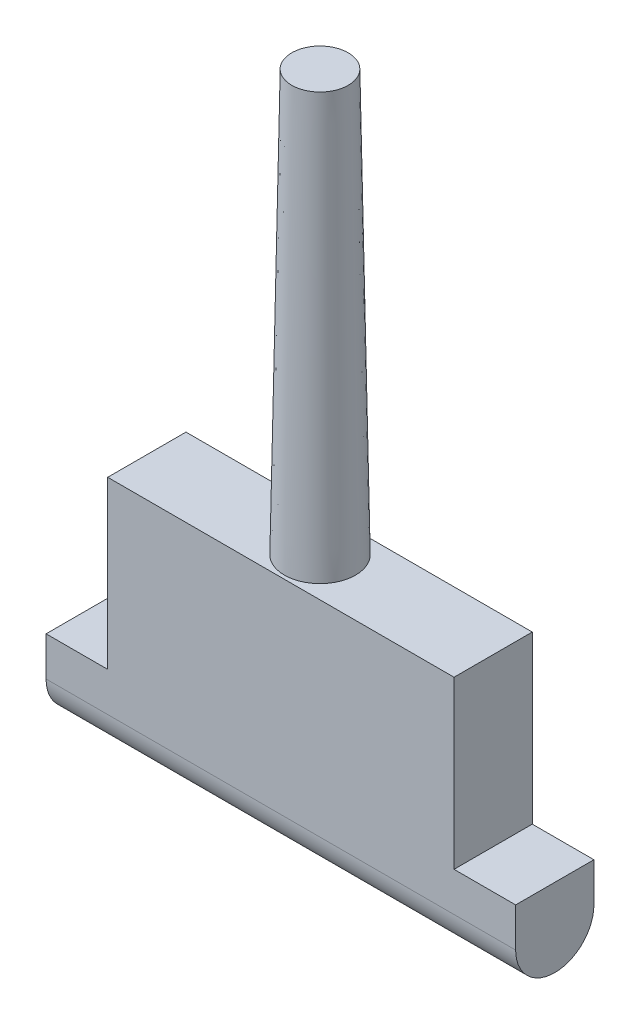
from build123d import *

# Parameters (mm, degrees)
BOSS_EXTRUDE1_DEPTH = 19.05
SKETCH2_R           = 3.175
BOSS_EXTRUDE2_DEPTH = 50.8
BOSS_EXTRUDE2_TAPER = 1
SKETCH3_W           = 28.1
SKETCH3_H           = 13.5
BOSS_EXTRUDE3_DEPTH = 3.175


with BuildPart() as part:
    # Sketch1 → Boss-Extrude1 (new body, symmetric)
    with BuildSketch(Plane(origin=(0, 0, 0), x_dir=(0, 0, -1), z_dir=(1, 0, 0))):
        with BuildLine():
            Line((-3.175, 0), (-3.175, 3.175))
            Line((-3.175, 3.175), (3.175, 3.175))
            Line((3.175, 3.175), (3.175, 0))
            ThreePointArc((3.175, 0), (0, -3.175), (-3.175, 0))
        make_face()
    extrude(amount=BOSS_EXTRUDE1_DEPTH, both=True)

    # Sketch2 → Boss-Extrude2 (add)
    with BuildSketch(Plane(origin=(0, 0, 0), x_dir=(1, 0, 0), z_dir=(0, 1, 0))):
        Circle(SKETCH2_R)
    extrude(amount=BOSS_EXTRUDE2_DEPTH, taper=BOSS_EXTRUDE2_TAPER)

    # Sketch3 → Boss-Extrude3 (add, symmetric)
    with BuildSketch(Plane.XY):
        with Locations((0, 9.925)):
            Rectangle(SKETCH3_W, SKETCH3_H)
    extrude(amount=BOSS_EXTRUDE3_DEPTH, both=True)


solid = part.part
